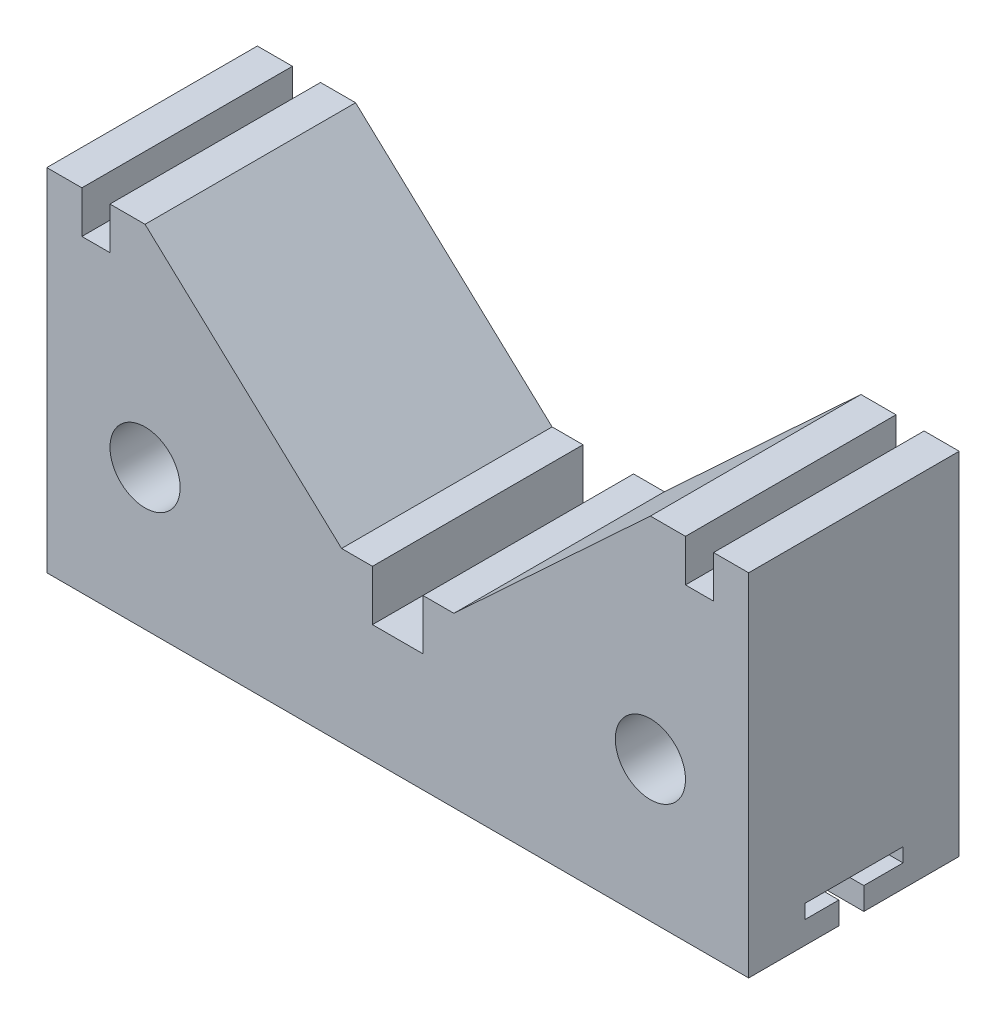
from build123d import *

# Parameters (mm, degrees)
SKETCH2_R           = 12.5
BOSS_EXTRUDE1_DEPTH = 37.5
CUT_EXTRUDE1_DEPTH  = 300


with BuildPart() as part:
    # Sketch2 → Boss-Extrude1 (new body, symmetric)
    with BuildSketch(Plane.XY):
        Polygon((-125, 0), (125, 0), (125, 125), (112.5, 125), (112.5, 110), (102.5, 110), (102.5, 125), (90, 125), (20, 60), (9, 60), (9, 42), (-9, 42), (-9, 60), (-20, 60), (-90, 125), (-102.5, 125), (-102.5, 110), (-112.5, 110), (-112.5, 125), (-125, 125), align=None)
        with Locations((-90, 50)):
            Circle(SKETCH2_R, mode=Mode.SUBTRACT)
        with Locations((90, 50)):
            Circle(SKETCH2_R, mode=Mode.SUBTRACT)
    extrude(amount=BOSS_EXTRUDE1_DEPTH, both=True)

    # Sketch3 → Cut-Extrude1 (cut)
    with BuildSketch(Plane(origin=(125, 0, 0), x_dir=(0, 0, -1), z_dir=(1, 0, 0))):
        Polygon((-17.5, 13), (17.5, 13), (17.5, 8), (3.530117055, 8), (3.530117055, 0), (-5.373528479, 0), (-5.373528479, 8), (-17.5, 8), align=None)
    extrude(amount=-CUT_EXTRUDE1_DEPTH, mode=Mode.SUBTRACT)


solid = part.part
